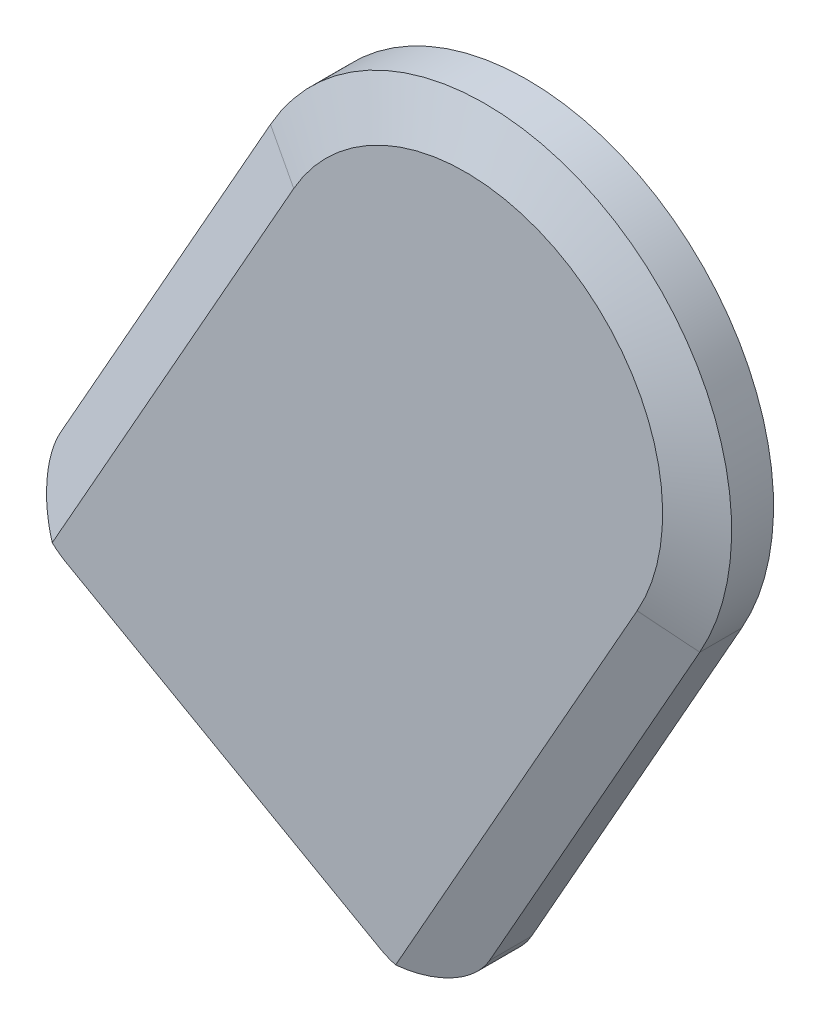
from build123d import *
from OCP.BRepFilletAPI import BRepFilletAPI_MakeChamfer

# Parameters (mm, degrees)
BOSS_EXTRUDE1_DEPTH = 4.7625
CHAMFER1_SIZE       = 1.524
CHAMFER1_SIZE2      = 3.81
FILLET1_R           = 5.08


with BuildPart() as part:
    # Sketch1 → Boss-Extrude1 (new body)
    with BuildSketch(Plane.XY):
        with BuildLine():
            Line((-16.586093498, 9.370378993), (-35.326851484, -23.801808003))
            Line((-35.326851484, -23.801808003), (-2.154664488, -42.542565989))
            Line((-2.154664488, -42.542565989), (16.586093498, -9.370378993))
            ThreePointArc((16.586093498, -9.370378993), (9.370378993, 16.586093498), (-16.586093498, 9.370378993))
        make_face()
    extrude(amount=BOSS_EXTRUDE1_DEPTH)

    # Chamfer1: one chamfer whose edges measure the first distance from different faces: ONE call of the kernel's chamfer builder (chamfer() names one face for all edges)
    chamfer1_edges_1 = [part.edges().sort_by_distance(p)[0] for p in [
        (7.215714505, -25.956472491, 4.7625),
    ]]
    chamfer1_side_1 = [part.faces().sort_by_distance(p)[0] for p in [
        (7.215714505, -25.956472491, 2.38125),
    ]]
    chamfer1_edges_2 = [part.edges().sort_by_distance(p)[0] for p in [
        (9.370378993, 16.586093498, 4.7625),
    ]]
    chamfer1_side_2 = [part.faces().sort_by_distance(p)[0] for p in [
        (9.370378993, 16.586093498, 2.38125),
    ]]
    chamfer1_edges_3 = [part.edges().sort_by_distance(p)[0] for p in [
        (-25.956472491, -7.215714505, 4.7625),
    ]]
    chamfer1_side_3 = [part.faces().sort_by_distance(p)[0] for p in [
        (-25.956472491, -7.215714505, 2.38125),
    ]]
    chamfer1 = BRepFilletAPI_MakeChamfer(part.part.solid().wrapped)
    for e in chamfer1_edges_1:
        chamfer1.Add(CHAMFER1_SIZE, CHAMFER1_SIZE2, e.wrapped, chamfer1_side_1[0].wrapped)  # the first distance lies on this face
    for e in chamfer1_edges_2:
        chamfer1.Add(CHAMFER1_SIZE, CHAMFER1_SIZE2, e.wrapped, chamfer1_side_2[0].wrapped)  # the first distance lies on this face
    for e in chamfer1_edges_3:
        chamfer1.Add(CHAMFER1_SIZE, CHAMFER1_SIZE2, e.wrapped, chamfer1_side_3[0].wrapped)  # the first distance lies on this face
    add(Compound.cast(chamfer1.Shape()), mode=Mode.REPLACE)

    # Fillet1
    fillet1_edges = [part.edges().sort_by_distance(p)[0] for p in [
        (-35.326851484, -23.801808003, 1.61925),
        (-2.154664488, -42.542565989, 1.61925),
    ]]
    fillet(fillet1_edges, radius=FILLET1_R)


solid = part.part
